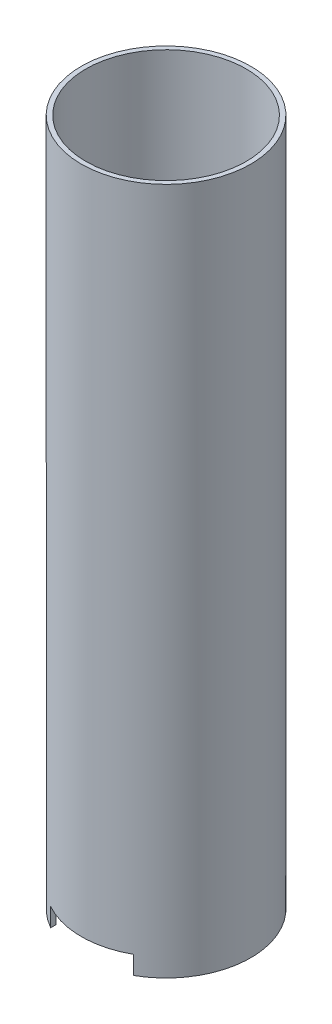
from build123d import *

# Parameters (mm, degrees)
SKETCH1_R          = 18.5
SKETCH1_R_2        = 17.5
SHELL_DEPTH        = 150
SKETCH8_R          = 17.5
SKETCH8_R_2        = 3.5
SKETCH8_R_3        = 6.5
RODALIGNER_DEPTH   = 1
CUT_EXTRUDE1_DEPTH = 4


with BuildPart() as part:
    # Sketch1 → Shell (new body)
    with BuildSketch(Plane(origin=(0, 0, 0), x_dir=(1, 0, 0), z_dir=(0, 1, 0))):
        Circle(SKETCH1_R)
        Circle(SKETCH1_R_2, mode=Mode.SUBTRACT)
    extrude(amount=SHELL_DEPTH)

    # Sketch8 → RodAligner (add, symmetric)
    with BuildSketch(Plane(origin=(0, 120, 0), x_dir=(1, 0, 0), z_dir=(0, 1, 0))):
        Circle(SKETCH8_R)
        with Locations((0, -12)):
            Circle(SKETCH8_R_2, mode=Mode.SUBTRACT)
        Circle(SKETCH8_R_3, mode=Mode.SUBTRACT)
    extrude(amount=RODALIGNER_DEPTH, both=True)

    # Sketch1_7 → Cut-Extrude1 (cut)
    with BuildSketch(Plane(origin=(0, 0, 0), x_dir=(1, 0, 0), z_dir=(0, 1, 0))):
        with BuildLine():
            Line((-9.013878189, 16.155494421), (-9.013878189, 15))
            ThreePointArc((-9.013878189, 15), (0, 17.5), (9.013878189, 15))
            Line((9.013878189, 15), (9.013878189, 16.155494421))
            ThreePointArc((9.013878189, 16.155494421), (0, 18.5), (-9.013878189, 16.155494421))
        make_face()
        with BuildLine():
            ThreePointArc((9.013878189, -15), (0, -17.5), (-9.013878189, -15))
            Line((-9.013878189, -15), (-9.013878189, -16.155494421))
            ThreePointArc((-9.013878189, -16.155494421), (0, -18.5), (9.013878189, -16.155494421))
            Line((9.013878189, -16.155494421), (9.013878189, -15))
        make_face()
    extrude(amount=CUT_EXTRUDE1_DEPTH, mode=Mode.SUBTRACT)


solid = part.part
